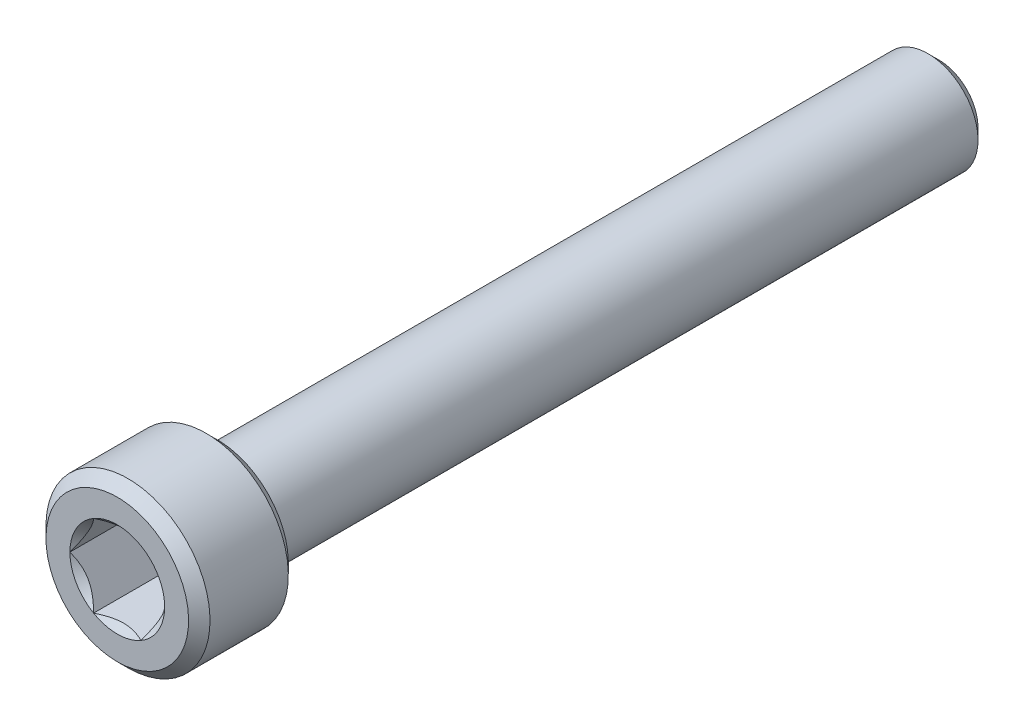
from build123d import *

# Parameters (mm, degrees)
CUT_EXTRUDE1_DEPTH = 3.6195


with BuildPart() as part:
    # Sketch2 → Revolve1 (revolve)
    with BuildSketch(Plane(origin=(0, 0, 0), x_dir=(0, 0, -1), z_dir=(1, 0, 0))):
        Polygon((-15.1384, 0), (24.6126, 0), (24.6126, 1.894416667), (24.094016667, 2.413), (-10.3124, 2.413), (-10.3124, 3.450166667), (-10.830983333, 3.96875), (-14.619816667, 3.96875), (-15.1384, 3.450166667), align=None)
    revolve(axis=Axis((0, 0, 10.3124), (0, 0, -1)))

    # Sketch3 → Cut-Extrude1 (cut)
    with BuildSketch(Plane.XY.offset(15.1384)):
        Polygon((1.14567944, 1.984375), (-1.14567944, 1.984375), (-2.291358881, 0), (-1.14567944, -1.984375), (1.14567944, -1.984375), (2.291358881, 0), align=None)
    extrude(amount=-CUT_EXTRUDE1_DEPTH, mode=Mode.SUBTRACT)

    # Cut-Extrude2 cone 1 section (through the dimple's axis) → Cut-Extrude2 (revolve, cut)
    with BuildSketch(Plane(origin=(0, 0, 15.1384), x_dir=(0, -1, 0), z_dir=(1, 0, 0))):
        Polygon((0, 0), (2.291358881, 0), (0, 2.291358881), align=None)
    revolve(axis=Axis((0, 0, 15.1384), (0, 0, -1)), mode=Mode.SUBTRACT)


solid = part.part
